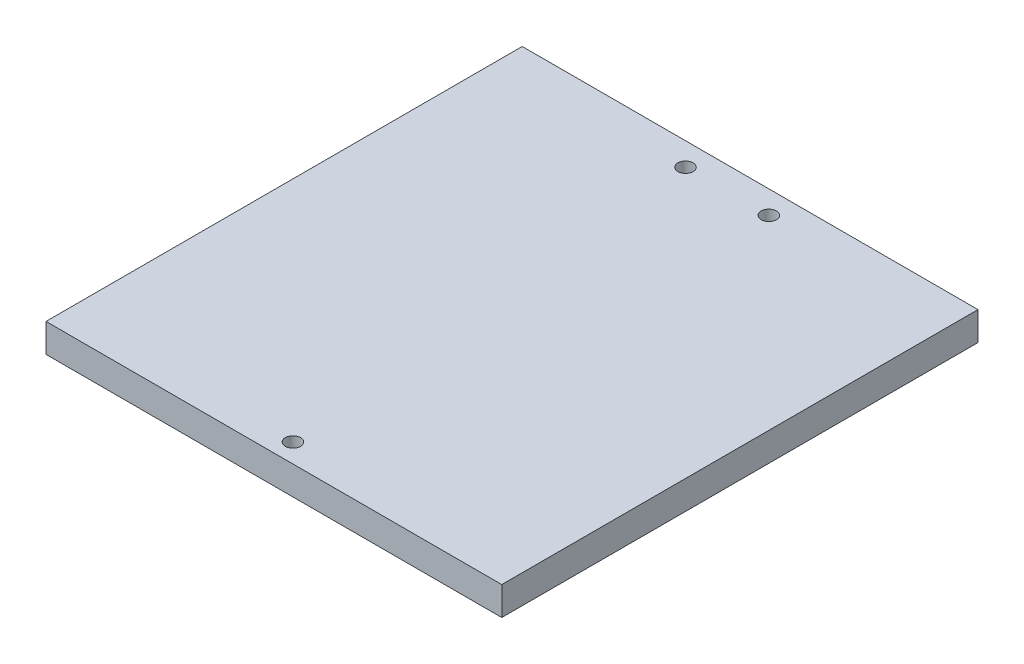
from build123d import *

# Parameters (mm, degrees)
SKETCH1_W           = 95.7
SKETCH1_H           = 100
SKETCH1_R           = 1.6
BOSS_EXTRUDE1_DEPTH = 3


with BuildPart() as part:
    # Sketch1 → Boss-Extrude1 (new body, symmetric)
    with BuildSketch(Plane(origin=(0, 0, 0), x_dir=(1, 0, 0), z_dir=(0, 1, 0))):
        Rectangle(SKETCH1_W, SKETCH1_H)
        with Locations((-8.75, 45.181367204)):
            Circle(SKETCH1_R, mode=Mode.SUBTRACT)
        with Locations((8.75, 45.181367204)):
            Circle(SKETCH1_R, mode=Mode.SUBTRACT)
        with Locations((0, -46)):
            Circle(SKETCH1_R, mode=Mode.SUBTRACT)
    extrude(amount=BOSS_EXTRUDE1_DEPTH, both=True)


solid = part.part
